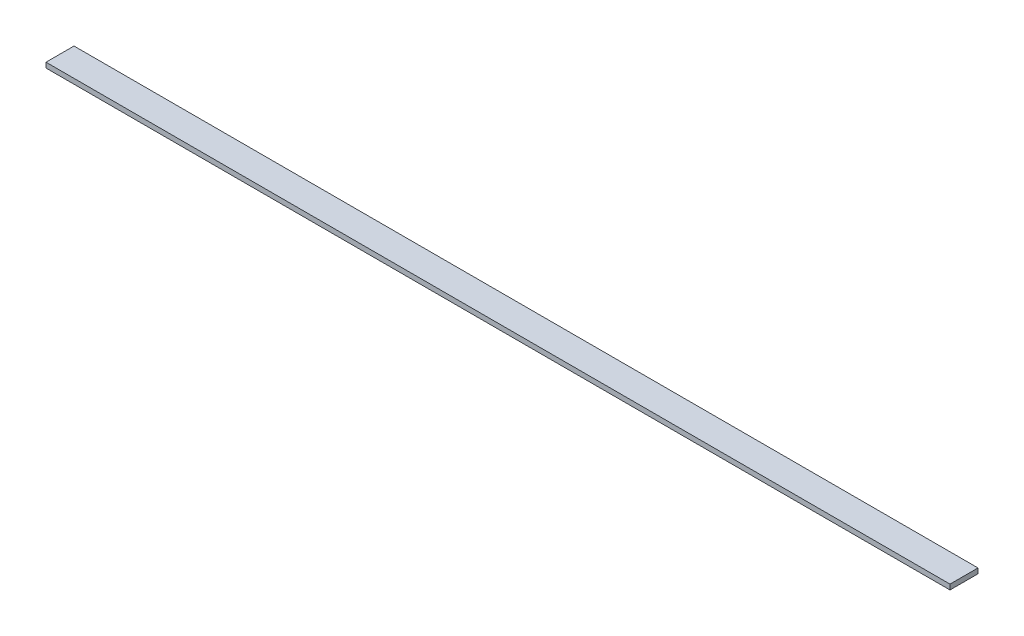
from build123d import *

# Parameters (mm, degrees)
SKETCH1_W           = 4508.5
SKETCH1_H           = 139.7
BOSS_EXTRUDE1_DEPTH = 25.4


with BuildPart() as part:
    # Sketch1 → Boss-Extrude1 (new body)
    with BuildSketch(Plane(origin=(0, 0, 0), x_dir=(1, 0, 0), z_dir=(0, 1, 0))):
        with Locations((2254.25, -69.85)):
            Rectangle(SKETCH1_W, SKETCH1_H)
    extrude(amount=BOSS_EXTRUDE1_DEPTH)


solid = part.part
